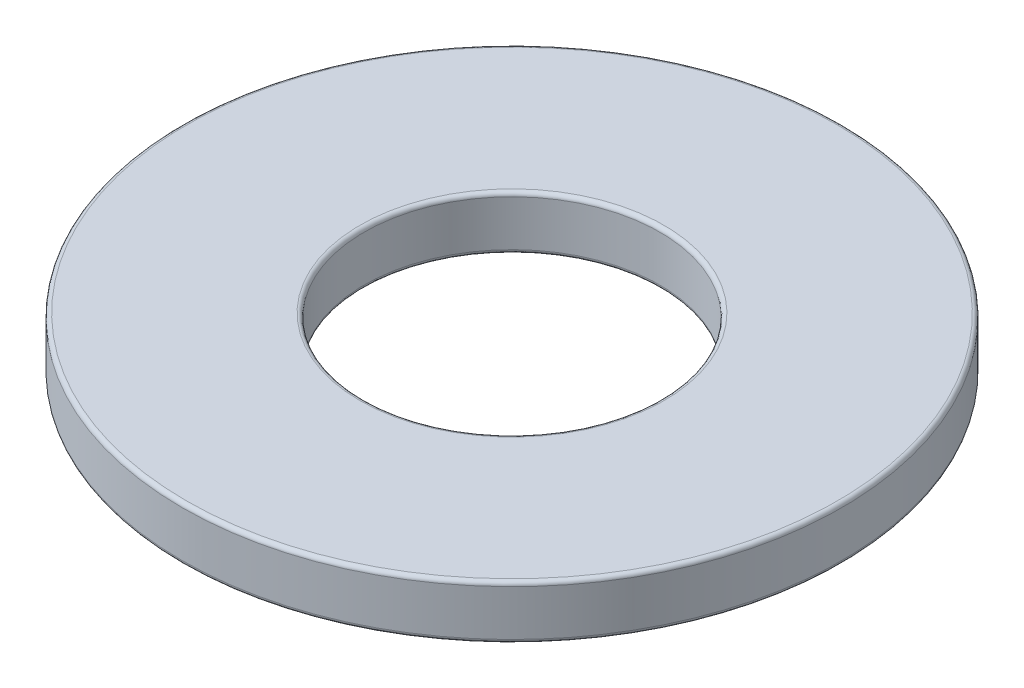
from build123d import *

# Parameters (mm, degrees)
SKETCH1_R           = 4.9
SKETCH1_R_2         = 2.2
BOSS_EXTRUDE1_DEPTH = 0.8
FILLET1_R           = 0.06


with BuildPart() as part:
    # Sketch1 → Boss-Extrude1 (new body)
    with BuildSketch(Plane(origin=(0, 0, 0), x_dir=(1, 0, 0), z_dir=(0, 1, 0))):
        Circle(SKETCH1_R)
        Circle(SKETCH1_R_2, mode=Mode.SUBTRACT)
    extrude(amount=BOSS_EXTRUDE1_DEPTH)

    # Fillet1
    fillet1_edges = [part.edges().sort_by_distance(p)[0] for p in [
        (-4.9, 0, 0),
        (-4.9, 0.8, 0),
        (-2.2, 0, 0),
        (-2.2, 0.8, 0),
    ]]
    fillet(fillet1_edges, radius=FILLET1_R)


solid = part.part
